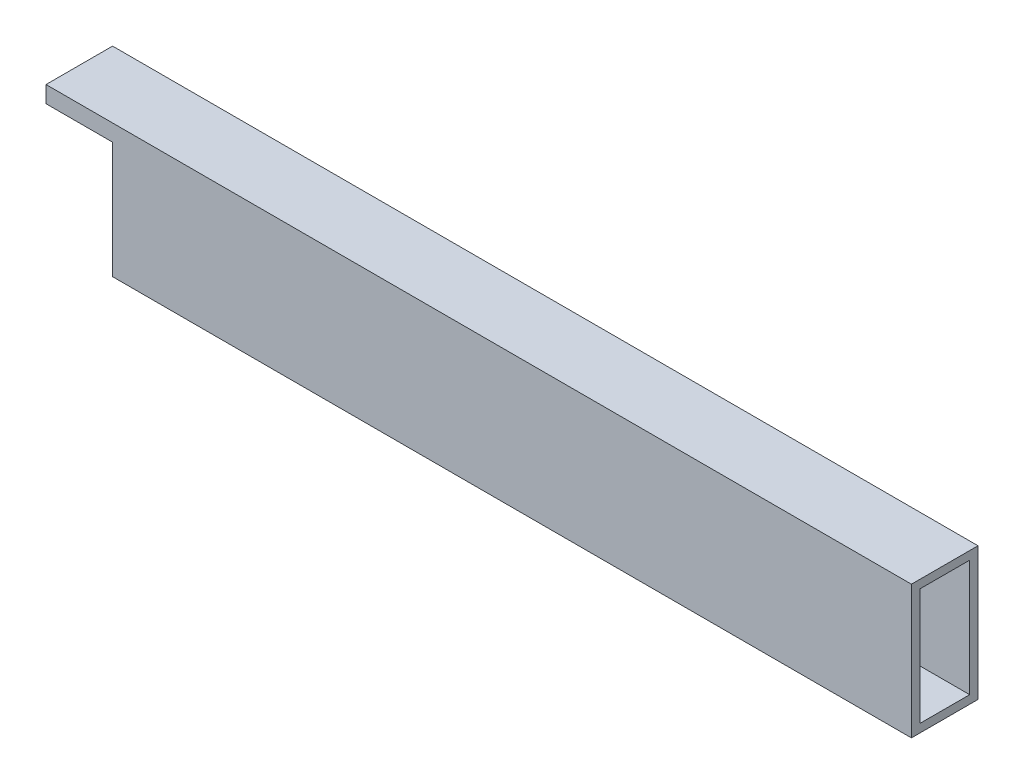
from build123d import *

# Parameters (mm, degrees)
SKETCH1_W           = 330.2
SKETCH1_H           = 25.4
BOSS_EXTRUDE4_DEPTH = 50.8
SKETCH5_W           = 19.05
SKETCH5_H           = 44.45
CUT_EXTRUDE1_DEPTH  = 330.2
SKETCH7_W           = 25.4
SKETCH7_H           = 44.45
CUT_EXTRUDE4_DEPTH  = 31.496


with BuildPart() as part:
    # Sketch1 → Boss-Extrude4 (new body)
    with BuildSketch(Plane(origin=(0, 0, 0), x_dir=(1, 0, 0), z_dir=(0, 1, 0))):
        with Locations((-165.1, -12.7)):
            Rectangle(SKETCH1_W, SKETCH1_H)
    extrude(amount=BOSS_EXTRUDE4_DEPTH)

    # Sketch5 → Cut-Extrude1 (cut)
    with BuildSketch(Plane.ZY.offset(330.2)):
        with Locations((12.7, 25.4)):
            Rectangle(SKETCH5_W, SKETCH5_H)
    extrude(amount=-CUT_EXTRUDE1_DEPTH, mode=Mode.SUBTRACT)

    # Sketch7 → Cut-Extrude4 (cut)
    with BuildSketch(Plane(origin=(0, 0, 0), x_dir=(-1, 0, 0), z_dir=(0, 0, -1))):
        with Locations((317.5, 22.225)):
            Rectangle(SKETCH7_W, SKETCH7_H)
    extrude(amount=-CUT_EXTRUDE4_DEPTH, mode=Mode.SUBTRACT)


solid = part.part
